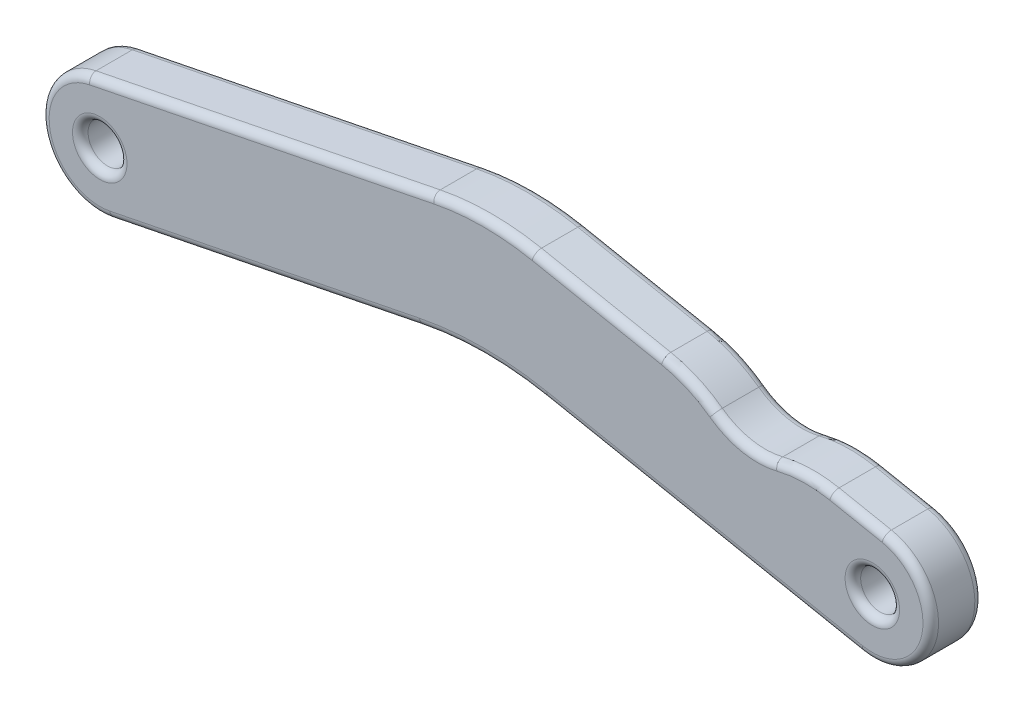
from build123d import *

# Parameters (mm, degrees)
SKETCH1_R               = 0.75
BOSS_EXTRUDE1_DEPTH     = 2
SKETCH3_OUTSIDE_W       = 43.2
SKETCH3_OUTSIDE_H       = 13.426
CUT_EXTRUDE4_DEPTH      = 3
SKETCH4_R               = 0.75
BOSS_EXTRUDE2_DEPTH     = 2
CUT_EXTRUDE6_DEPTH      = 3
CUT_EXTRUDE6_DEPTH_BACK = 1
FILLET1_R               = 0.3


with BuildPart() as part:
    # Sketch1 → Boss-Extrude1 (new body)
    with BuildSketch(Plane.XY):
        with BuildLine():
            Line((0, 2.25), (29.773744, 2.25))
            ThreePointArc((29.773744, 2.25), (32.023744, 0), (29.773744, -2.25))
            Line((29.773744, -2.25), (0, -2.25))
            ThreePointArc((0, -2.25), (-2.25, 0), (0, 2.25))
        make_face()
        Circle(SKETCH1_R, mode=Mode.SUBTRACT)
        with Locations((29.773744, 0)):
            Circle(SKETCH1_R, mode=Mode.SUBTRACT)
    extrude(amount=BOSS_EXTRUDE1_DEPTH)

    # Sketch3 outside → Cut-Extrude4 (cut, through all)
    with BuildSketch(Plane.XY):
        with Locations((14.887, 0)):
            Rectangle(SKETCH3_OUTSIDE_W, SKETCH3_OUTSIDE_H)
        with BuildLine():
            Line((0.442179, -2.206123), (12.375705, 0.185745))
            ThreePointArc((12.375705, 0.185745), (14.779441, 0.425999), (17.183853, 0.192609))
            Line((17.183853, 0.192609), (29.337866, -2.207376))
            ThreePointArc((29.337866, -2.207376), (31.98112, -0.435878), (30.209622, 2.207376))
            Line((30.209622, 2.207376), (16.724339, 4.87024))
            ThreePointArc((16.724339, 4.87024), (14.772826, 5.059669), (12.821862, 4.864669))
            Line((12.821862, 4.864669), (-0.442179, 2.206123))
            ThreePointArc((-0.442179, 2.206123), (-2.206123, -0.442179), (0.442179, -2.206123))
        make_face(mode=Mode.SUBTRACT)
    extrude(amount=CUT_EXTRUDE4_DEPTH, mode=Mode.SUBTRACT)

    # Sketch4 → Boss-Extrude2 (add)
    with BuildSketch(Plane.XY.offset(2)):
        with BuildLine():
            Line((12.821862, 4.864669), (-0.442179, 2.206123))
            ThreePointArc((-0.442179, 2.206123), (-2.206123, -0.442179), (0.442179, -2.206123))
            Line((0.442179, -2.206123), (12.375705, 0.185745))
            ThreePointArc((12.375705, 0.185745), (14.779441, 0.425999), (17.183853, 0.192609))
            Line((17.183853, 0.192609), (29.337866, -2.207376))
            ThreePointArc((29.337866, -2.207376), (31.98112, -0.435878), (30.209622, 2.207376))
            Line((30.209622, 2.207376), (16.724339, 4.87024))
            ThreePointArc((16.724339, 4.87024), (14.772826, 5.059669), (12.821862, 4.864669))
        make_face()
        with Locations((29.773744, 0)):
            Circle(SKETCH4_R, mode=Mode.SUBTRACT)
        Circle(SKETCH4_R, mode=Mode.SUBTRACT)
    extrude(amount=-BOSS_EXTRUDE2_DEPTH)

    # Sketch6 → Cut-Extrude6 (cut, two sides)
    with BuildSketch(Plane.XY) as cut_extrude6_sk:
        with BuildLine():
            Line((28.192659, 2.605655), (29.051924, 2.43598))
            Line((29.051924, 2.43598), (30.900687, 7.274865))
            Line((30.900687, 7.274865), (20.274115, 7.715344))
            Line((20.274115, 7.715344), (20.939885, 4.03782))
            Line((20.939885, 4.03782), (21.707391, 3.886264))
            ThreePointArc((21.707391, 3.886264), (22.748987, 3.559088), (23.694739, 3.013634))
            ThreePointArc((23.694739, 3.013634), (24.807653, 2.52496), (26.022784, 2.553928))
            ThreePointArc((26.022784, 2.553928), (27.104881, 2.698954), (28.192659, 2.605655))
        make_face()
    extrude(amount=CUT_EXTRUDE6_DEPTH, mode=Mode.SUBTRACT)
    extrude(cut_extrude6_sk.sketch, amount=-CUT_EXTRUDE6_DEPTH_BACK, mode=Mode.SUBTRACT)

    # Fillet1
    fillet1_edges = [part.edges().sort_by_distance(p)[0] for p in [
        (29.023744, 0, 0),
        (-0.75, 0, 0),
        (6.408942, -1.010189, 0),
        (14.779441, 0.425999, 0),
        (23.260859, -1.007384, 0),
        (32.013063, -0.218979, 0),
        (14.772826, 5.059669, 2),
        (14.772826, 5.059669, 0),
        (6.189842, 3.535396, 2),
        (6.189842, 3.535396, 0),
        (-2.239004, -0.222175, 0),
        (29.023744, 0, 2),
        (-0.75, 0, 2),
        (32.013063, -0.218979, 2),
        (23.260859, -1.007384, 2),
        (14.779441, 0.425999, 2),
        (6.408942, -1.010189, 2),
        (-2.239004, -0.222175, 2),
        (18.832112, 4.45403, 2),
        (18.832112, 4.45403, 0),
        (29.630773, 2.321678, 0),
        (29.630773, 2.321678, 2),
        (22.748987, 3.559088, 0),
        (27.104881, 2.698954, 0),
        (24.807653, 2.52496, 0),
        (22.748987, 3.559088, 2),
        (24.807653, 2.52496, 2),
        (27.104881, 2.698954, 2),
    ]]
    fillet(fillet1_edges, radius=FILLET1_R)


solid = part.part
